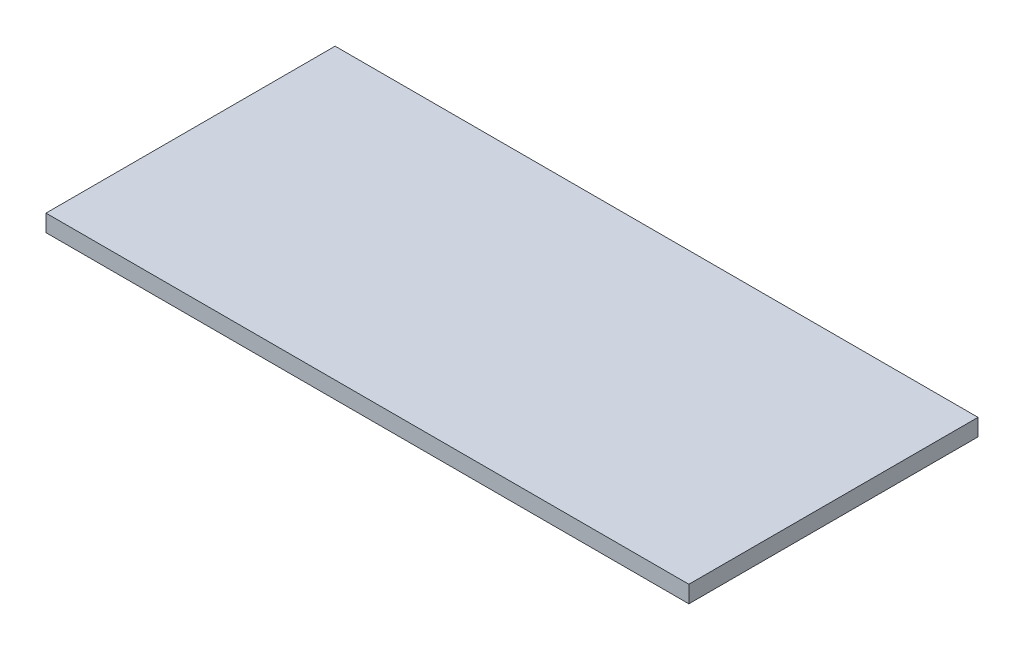
from build123d import *

# Parameters (mm, degrees)
SKETCH1_W           = 60.1472
SKETCH1_H           = 27.051
BOSS_EXTRUDE1_DEPTH = 1.5875


with BuildPart() as part:
    # Sketch1 → Boss-Extrude1 (new body)
    with BuildSketch(Plane(origin=(0, 0, 0), x_dir=(1, 0, 0), z_dir=(0, 1, 0))):
        with Locations((30.0736, 13.5255)):
            Rectangle(SKETCH1_W, SKETCH1_H)
    extrude(amount=BOSS_EXTRUDE1_DEPTH)


solid = part.part
